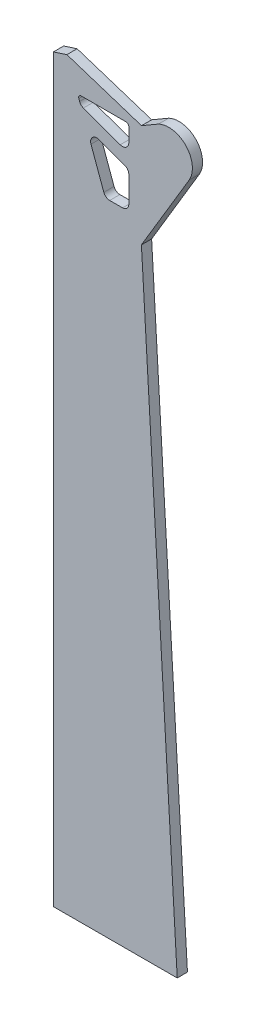
from build123d import *

# Parameters (mm, degrees)
BOSS_EXTRUDE6_DEPTH = 4


with BuildPart() as part:
    # Sketch20 → Boss-Extrude6 (new body)
    with BuildSketch(Plane.XY):
        with BuildLine():
            Line((36.624785701, -24.701414589), (17.902939914, -56.058435219))
            Line((17.902939914, -56.058435219), (31.951161852, -297.999999834))
            Line((31.951161852, -297.999999834), (-16.59209867, -298.052484048))
            Line((-16.59209867, -298.052484048), (-16.59209867, -7.784403475))
            Line((-16.59209867, -7.784403475), (-11.309666824, -6.069762931))
            Line((-11.309666824, -6.069762931), (17.938518552, -15.571491158))
            Line((17.938518552, -15.571491158), (24.592593053, -11.700714256))
            ThreePointArc((24.592593053, -11.700714256), (35.424716451, -13.743814885), (36.624785701, -24.701414589))
        make_face()
        with BuildLine():
            Line((-6.6408348, -18.644095931), (-6.337063012, -19.478702059))
            ThreePointArc((-6.337063012, -19.478702059), (-5.755598413, -20.391418654), (-4.842881819, -20.972883253))
            Line((-4.842881819, -20.972883253), (9.594949642, -26.227824152))
            ThreePointArc((9.594949642, -26.227824152), (11.883941091, -25.92647271), (12.95, -23.8785926))
            Line((12.95, -23.8785926), (12.95, -18.302075788))
            ThreePointArc((12.95, -18.302075788), (12.657106781, -17.594969007), (11.95, -17.302075788))
            Line((11.95, -17.302075788), (-5.701142179, -17.302075788))
            ThreePointArc((-5.701142179, -17.302075788), (-6.520294224, -17.728499352), (-6.6408348, -18.644095931))
        make_face(mode=Mode.SUBTRACT)
        with BuildLine():
            Line((-1.8643328, -31.767427321), (3.165925841, -45.587949351))
            ThreePointArc((3.165925841, -45.587949351), (4.062910493, -46.756922509), (5.468172762, -47.2))
            Line((5.468172762, -47.2), (10.5, -47.2))
            ThreePointArc((10.5, -47.2), (12.232411614, -46.482411614), (12.95, -44.75))
            Line((12.95, -44.75), (12.95, -34.591777725))
            ThreePointArc((12.95, -34.591777725), (12.506922509, -33.186515456), (11.337949351, -32.289530804))
            Line((11.337949351, -32.289530804), (1.275863472, -28.627231049))
            ThreePointArc((1.275863472, -28.627231049), (-1.294497493, -29.197066356), (-1.8643328, -31.767427321))
        make_face(mode=Mode.SUBTRACT)
    extrude(amount=BOSS_EXTRUDE6_DEPTH)


solid = part.part
